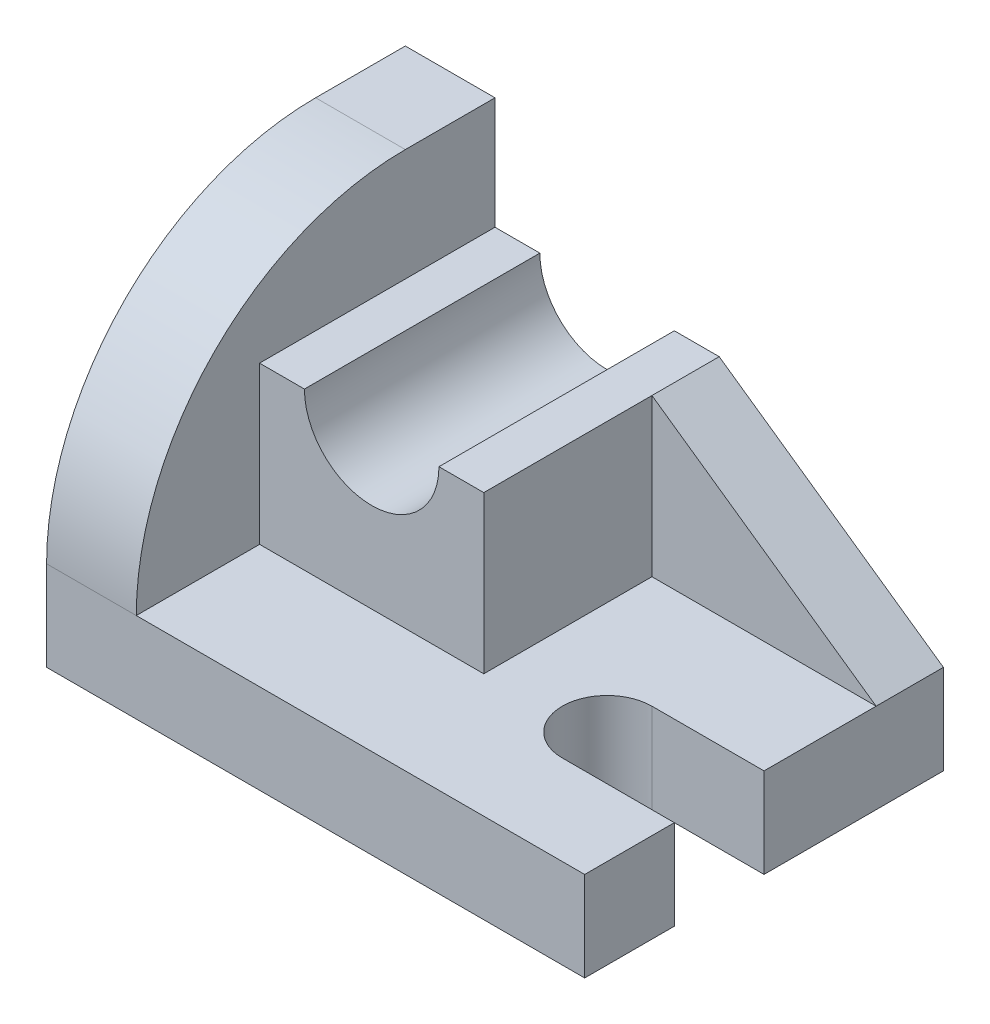
from build123d import *

# Parameters (mm, degrees)
SKETCH1_W           = 96
SKETCH1_H           = 64
BOSS_EXTRUDE1_DEPTH = 16
CUT_EXTRUDE1_DEPTH  = 16
BOSS_EXTRUDE2_DEPTH = 16
SKETCH4_W           = 40
SKETCH4_H           = 42
BOSS_EXTRUDE3_DEPTH = 28
CUT_EXTRUDE2_REACH  = 44
SKETCH5_R           = 12
BOSS_EXTRUDE4_DEPTH = 12


with BuildPart() as part:
    # Sketch1 → Boss-Extrude1 (new body)
    with BuildSketch(Plane(origin=(0, 0, 0), x_dir=(1, 0, 0), z_dir=(0, 1, 0))):
        with Locations((48, 32)):
            Rectangle(SKETCH1_W, SKETCH1_H)
    extrude(amount=BOSS_EXTRUDE1_DEPTH)

    # Sketch2 → Cut-Extrude1 (cut)
    with BuildSketch(Plane(origin=(0, 16, 0), x_dir=(1, 0, 0), z_dir=(0, 1, 0))):
        with BuildLine():
            Line((96, 16), (76, 16))
            ThreePointArc((76, 16), (68, 24), (76, 32))
            Line((76, 32), (96, 32))
            ThreePointArc((96, 32), (104, 24), (96, 16))
        make_face()
    extrude(amount=-CUT_EXTRUDE1_DEPTH, mode=Mode.SUBTRACT)

    # Sketch3 → Boss-Extrude2 (add)
    with BuildSketch(Plane.ZY):
        with BuildLine():
            Line((0, 0), (-64, 0))
            Line((-64, 0), (-64, 64))
            Line((-64, 64), (-48, 64))
            ThreePointArc((-48, 64), (-14.058874503, 49.941125497), (0, 16))
            Line((0, 16), (0, 0))
        make_face()
    extrude(amount=-BOSS_EXTRUDE2_DEPTH)

    # Sketch4 → Boss-Extrude3 (add)
    with BuildSketch(Plane(origin=(0, 16, 0), x_dir=(1, 0, 0), z_dir=(0, 1, 0))):
        with Locations((36, 43)):
            Rectangle(SKETCH4_W, SKETCH4_H)
    extrude(amount=BOSS_EXTRUDE3_DEPTH)

    # Sketch5 → Cut-Extrude2 (cut, up to next)
    with BuildSketch(Plane.XY.offset(-22), mode=Mode.PRIVATE) as cut_extrude2_sk1:
        with Locations((36, 44)):
            Circle(SKETCH5_R)
    cut_extrude2_tool1 = extrude(cut_extrude2_sk1.sketch, amount=-CUT_EXTRUDE2_REACH, mode=Mode.PRIVATE) & part.part
    add(cut_extrude2_tool1.solids().sort_by_distance((36, 44, -22))[0], mode=Mode.SUBTRACT)


with BuildPart() as body_2:
    # Sketch6 → Boss-Extrude4 (new body)
    with BuildSketch(Plane(origin=(0, 0, -64), x_dir=(-1, 0, 0), z_dir=(0, 0, -1))):
        Polygon((-56, 44), (-96, 16), (-56, 16), align=None)
    extrude(amount=-BOSS_EXTRUDE4_DEPTH)


solid = Compound([part.part, body_2.part])
